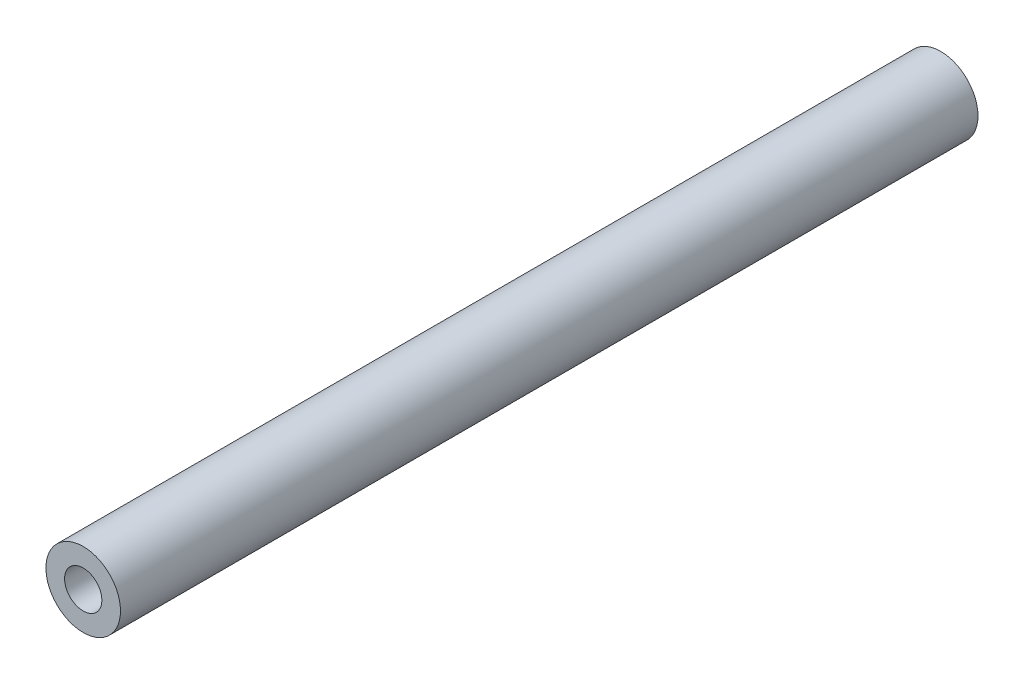
from build123d import *

# Parameters (mm, degrees)
SKETCH1_R           = 2
SKETCH1_R_2         = 1
BOSS_EXTRUDE1_DEPTH = 46


with BuildPart() as part:
    # Sketch1 → Boss-Extrude1 (new body)
    with BuildSketch(Plane.XY):
        Circle(SKETCH1_R)
        Circle(SKETCH1_R_2, mode=Mode.SUBTRACT)
    extrude(amount=BOSS_EXTRUDE1_DEPTH)


solid = part.part
